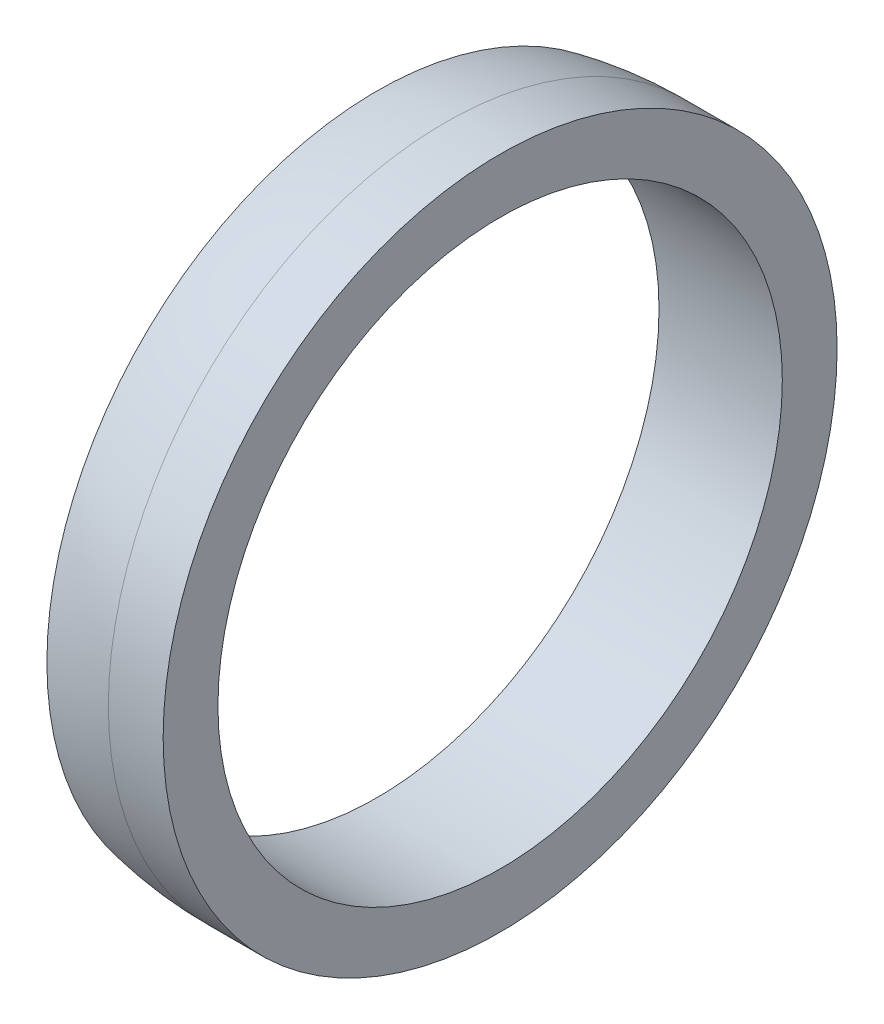
from build123d import *

# Parameters (mm, degrees)
SKIZZE4_R                       = 246
SKIZZE4_R_2                     = 206
AUFSATZ_LINEAR_AUSTRAGEN1_DEPTH = 40


with BuildPart() as part:
    # Skizze2 → Rotation1 (revolve)
    with BuildSketch(Plane.XY):
        with BuildLine():
            Line((0, 246), (0, 206))
            Line((0, 206), (-50, 206))
            Line((-50, 206), (-50, 240.865107477))
            ThreePointArc((-50, 240.865107477), (-25.131489815, 244.712909794), (0, 246))
        make_face()
    revolve(axis=Axis((0, 0, 0), (1, 0, 0)))

    # Skizze4 → Aufsatz-Linear austragen1 (add)
    with BuildSketch(Plane(origin=(0, 0, 0), x_dir=(0, 0, -1), z_dir=(1, 0, 0))):
        Circle(SKIZZE4_R)
        Circle(SKIZZE4_R_2, mode=Mode.SUBTRACT)
    extrude(amount=AUFSATZ_LINEAR_AUSTRAGEN1_DEPTH)


solid = part.part
